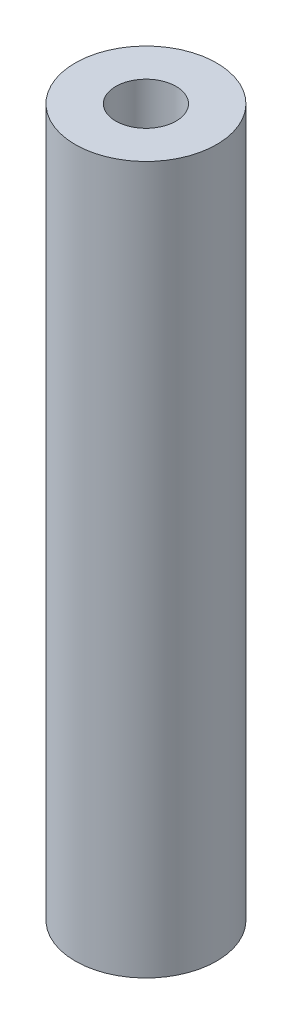
from build123d import *

# Parameters (mm, degrees)
SKETCH1_R                 = 3.175
BOSS_EXTRUDE1_DEPTH       = 31.75
TAP_DRILL_FOR_6_32_TAP1_D = 2.7051


with BuildPart() as part:
    # Sketch1 → Boss-Extrude1 (new body)
    with BuildSketch(Plane(origin=(0, 0, 0), x_dir=(1, 0, 0), z_dir=(0, 1, 0))):
        Circle(SKETCH1_R)
    extrude(amount=BOSS_EXTRUDE1_DEPTH)

    # Tap Drill for #6-32 Tap1 (through all)
    with Locations(Plane(origin=(0, 31.75, 0), x_dir=(1, 0, 0), z_dir=(0, 1, 0))):
        with Locations((0, 0)):
            Hole(TAP_DRILL_FOR_6_32_TAP1_D / 2)


solid = part.part
